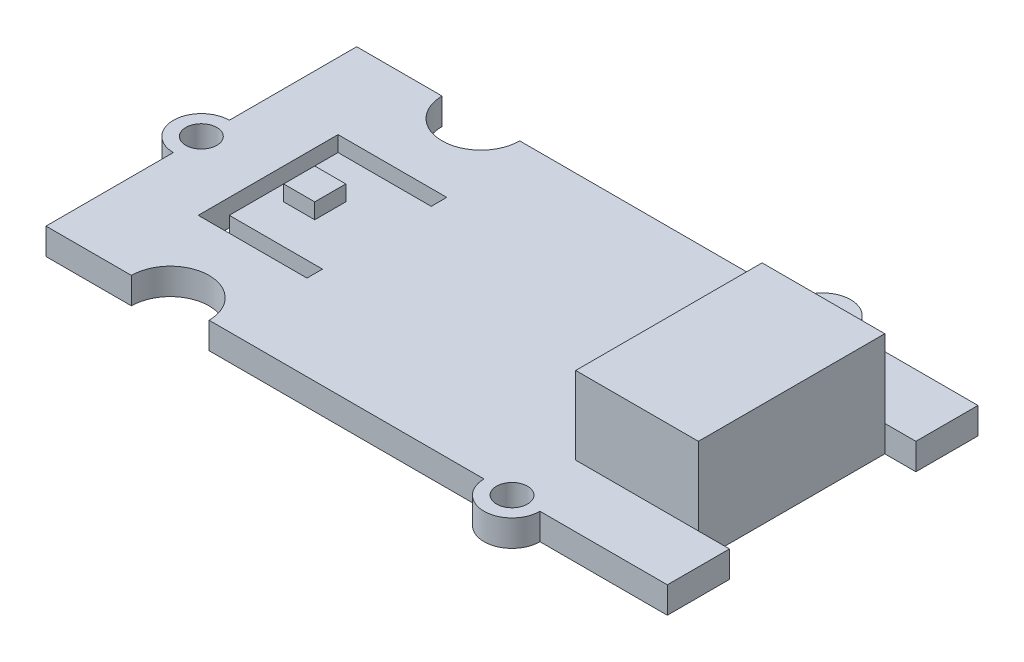
from build123d import *

# Parameters (mm, degrees)
SKETCH1_R           = 1
BOSS_EXTRUDE1_DEPTH = 1.7
SKETCH2_W           = 2
SKETCH2_H           = 2
BOSS_EXTRUDE2_DEPTH = 1
SKETCH3_W           = 7.9
SKETCH3_H           = 12
BOSS_EXTRUDE3_DEPTH = 5


with BuildPart() as part:
    # Sketch1 → Boss-Extrude1 (new body)
    with BuildSketch(Plane(origin=(0, 0, 0), x_dir=(1, 0, 0), z_dir=(0, 1, 0))):
        with BuildLine():
            Line((0, 0), (0, 8.2))
            ThreePointArc((0, 8.2), (-1.8, 10), (0, 11.8))
            Line((0, 11.8), (0, 20))
            Line((0, 20), (5.5, 20))
            ThreePointArc((5.5, 20), (8, 17.5), (10.5, 20))
            Line((10.5, 20), (28.2, 20))
            ThreePointArc((28.2, 20), (30, 21.8), (31.8, 20))
            Line((31.8, 20), (40, 20))
            Line((40, 20), (40, 16))
            Line((40, 16), (38, 16))
            Line((38, 16), (38, 4))
            Line((38, 4), (40, 4))
            Line((40, 4), (40, 0))
            Line((40, 0), (31.8, 0))
            ThreePointArc((31.8, 0), (30, -1.8), (28.2, 0))
            Line((28.2, 0), (10.5, 0))
            ThreePointArc((10.5, 0), (8, 2.5), (5.5, 0))
            Line((5.5, 0), (0, 0))
        make_face()
        with Locations((0, 10)):
            Circle(SKETCH1_R, mode=Mode.SUBTRACT)
        with Locations((30, 0)):
            Circle(SKETCH1_R, mode=Mode.SUBTRACT)
        with Locations((30, 20)):
            Circle(SKETCH1_R, mode=Mode.SUBTRACT)
        Polygon((4.3, 14.5), (11.3, 14.5), (11.3, 13.5), (5.3, 13.5), (5.3, 6.5), (11.3, 6.5), (11.3, 5.5), (4.3, 5.5), align=None, mode=Mode.SUBTRACT)
    extrude(amount=BOSS_EXTRUDE1_DEPTH)

    # Sketch2 → Boss-Extrude2 (add)
    with BuildSketch(Plane(origin=(0, 1.7, 0), x_dir=(1, 0, 0), z_dir=(0, 1, 0))):
        with Locations((7.3, 10)):
            Rectangle(SKETCH2_W, SKETCH2_H)
    extrude(amount=BOSS_EXTRUDE2_DEPTH)

    # Sketch3 → Boss-Extrude3 (add)
    with BuildSketch(Plane(origin=(0, 1.7, 0), x_dir=(1, 0, 0), z_dir=(0, 1, 0))):
        with Locations((34.05, 10)):
            Rectangle(SKETCH3_W, SKETCH3_H)
    extrude(amount=BOSS_EXTRUDE3_DEPTH)


solid = part.part
